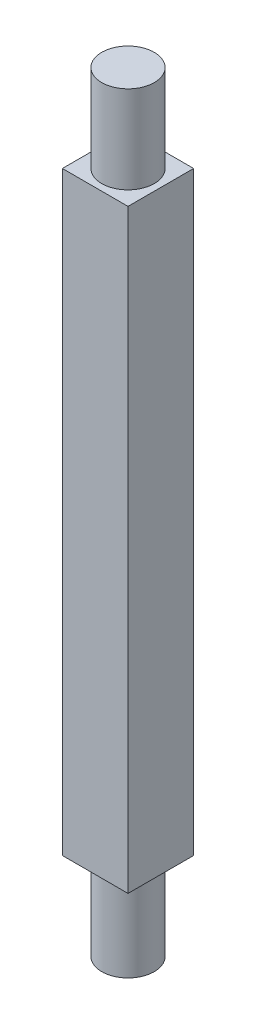
from build123d import *

# Parameters (mm, degrees)
SKETCH_1_W      = 15
SKETCH_1_H      = 15
EXTRUDE_1_DEPTH = 136
SKETCH_2_R      = 6
EXTRUDE_2_DEPTH = 20
SKETCH_3_R      = 6
EXTRUDE_3_DEPTH = 20


with BuildPart() as part:
    # 草图1 → 凸台-拉伸1 (new body)
    with BuildSketch(Plane(origin=(0, 0, 0), x_dir=(1, 0, 0), z_dir=(0, 1, 0))):
        Rectangle(SKETCH_1_W, SKETCH_1_H)
    extrude(amount=EXTRUDE_1_DEPTH)

    # 草图2 → 凸台-拉伸2 (add)
    with BuildSketch(Plane(origin=(0, 136, 0), x_dir=(1, 0, 0), z_dir=(0, 1, 0))):
        Circle(SKETCH_2_R)
    extrude(amount=EXTRUDE_2_DEPTH)

    # 草图3 → 凸台-拉伸3 (add)
    with BuildSketch(Plane.XZ):
        Circle(SKETCH_3_R)
    extrude(amount=EXTRUDE_3_DEPTH)


solid = part.part
